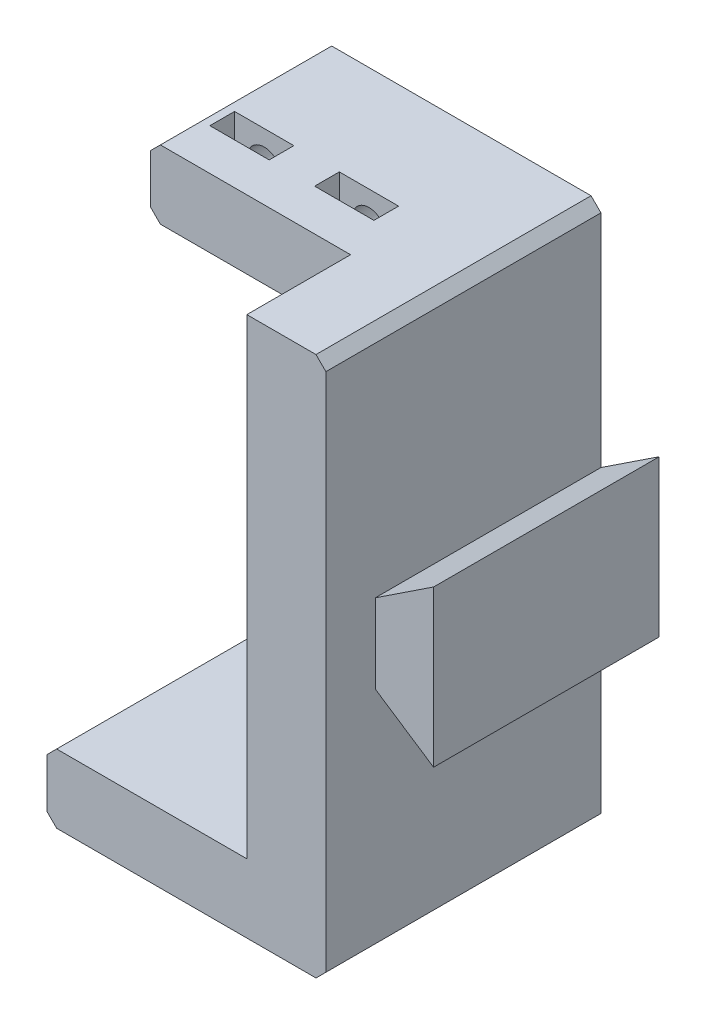
from build123d import *

# Parameters (mm, degrees)
BOSS_EXTRUDE1_DEPTH      = 27.84
SKETCH6_R                = 1.7
CUT_EXTRUDE1_DEPTH       = 13.15
SKETCH7_W                = 6
SKETCH7_H                = 2.5
CUT_EXTRUDE2_DEPTH       = 6
CHAMFER1_SIZE            = 1
CHAMFER1_OF_MIRROR2_SIZE = 1
SKETCH8_W                = 5
SKETCH8_H                = 15.8
CUT_EXTRUDE3_DEPTH       = 6.9
CUT_EXTRUDE4_REACH       = 56.65
SKETCH9_W                = 20.25
SKETCH9_H                = 10.5


with BuildPart() as part:
    # Sketch5 → Boss-Extrude1 (new body)
    with BuildSketch(Plane.XY):
        Polygon((8, 4), (8, 0), (13.9, 0), (13.9, 7.9), align=None)
        Polygon((-20.25, 27.325), (-20.25, 20.375), (0, 20.375), (0, 0), (8, 0), (8, 27.325), align=None)
    boss_extrude1 = extrude(amount=BOSS_EXTRUDE1_DEPTH)

    # Sketch6 → Cut-Extrude1 (cut)
    with BuildSketch(Plane(origin=(0, 0, 0), x_dir=(-1, 0, 0), z_dir=(0, 0, -1))):
        with Locations((4.83, 24.005)):
            Circle(SKETCH6_R)
        with Locations((15.43, 24.005)):
            Circle(SKETCH6_R)
    cut_extrude1 = extrude(amount=-CUT_EXTRUDE1_DEPTH, mode=Mode.SUBTRACT)

    # Sketch7 → Cut-Extrude2 (cut)
    with BuildSketch(Plane(origin=(0, 27.325, 0), x_dir=(1, 0, 0), z_dir=(0, 1, 0))):
        with Locations((-4.83, -11.9)):
            Rectangle(SKETCH7_W, SKETCH7_H)
        with Locations((-15.43, -11.9)):
            Rectangle(SKETCH7_W, SKETCH7_H)
    cut_extrude2 = extrude(amount=-CUT_EXTRUDE2_DEPTH, mode=Mode.SUBTRACT)

    # Chamfer1
    chamfer1_edges = [part.edges().sort_by_distance(p)[0] for p in [
        (-20.25, 20.375, 13.92),
        (-20.25, 27.325, 13.92),
        (8, 27.325, 13.92),
    ]]
    chamfer(chamfer1_edges, length=CHAMFER1_SIZE)

    # Mirror2: Boss-Extrude1, Cut-Extrude1, Cut-Extrude2 across plane
    add(boss_extrude1.mirror(Plane(origin=(0, 0, 27.84), x_dir=(0, 0, 1), z_dir=(0, -1, 0))))
    add(cut_extrude1.mirror(Plane(origin=(0, 0, 27.84), x_dir=(0, 0, 1), z_dir=(0, -1, 0))), mode=Mode.SUBTRACT)
    add(cut_extrude2.mirror(Plane(origin=(0, 0, 27.84), x_dir=(0, 0, 1), z_dir=(0, -1, 0))), mode=Mode.SUBTRACT)

    # Chamfer1 of Mirror2
    chamfer1_of_mirror2_edges = [part.edges().sort_by_distance(p)[0] for p in [
        (-20.25, -20.375, 13.92),
        (-20.25, -27.325, 13.92),
        (8, -27.325, 13.92),
    ]]
    chamfer(chamfer1_of_mirror2_edges, length=CHAMFER1_OF_MIRROR2_SIZE)

    # Sketch8 → Cut-Extrude3 (cut, through all)
    with BuildSketch(Plane(origin=(8, 0, 0), x_dir=(0, 0, -1), z_dir=(1, 0, 0))):
        with Locations((-25.34, 0)):
            Rectangle(SKETCH8_W, SKETCH8_H)
    extrude(amount=CUT_EXTRUDE3_DEPTH, mode=Mode.SUBTRACT)

    # Sketch9 → Cut-Extrude4 (cut, up to next)
    with BuildSketch(Plane(origin=(0, 27.325, 0), x_dir=(1, 0, 0), z_dir=(0, 1, 0)), mode=Mode.PRIVATE) as cut_extrude4_sk1:
        with Locations((-10.125, -22.59)):
            Rectangle(SKETCH9_W, SKETCH9_H)
    cut_extrude4_tool1 = extrude(cut_extrude4_sk1.sketch, amount=-CUT_EXTRUDE4_REACH, mode=Mode.PRIVATE) & part.part
    add(cut_extrude4_tool1.solids().sort_by_distance((-10.125, 27.325, 22.59))[0], mode=Mode.SUBTRACT)


solid = part.part
